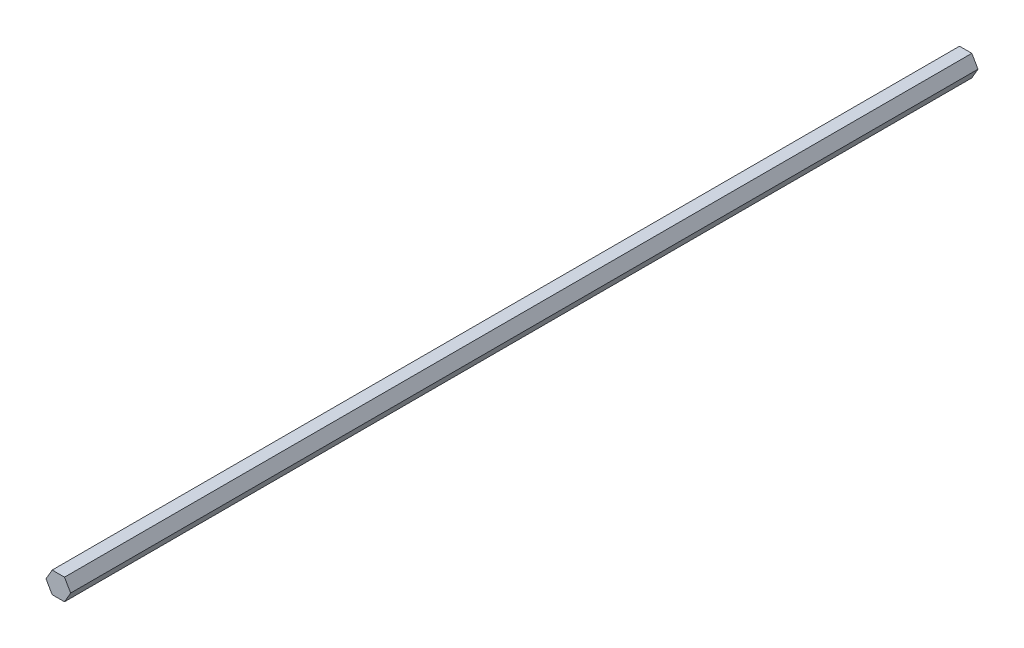
from build123d import *

# Parameters (mm, degrees)
BOSS_EXTRUDE1_DEPTH = 539.75


with BuildPart() as part:
    # Sketch1 → Boss-Extrude1 (new body)
    with BuildSketch(Plane.XY):
        Polygon((7.332348419, 0), (3.666174209, 6.35), (-3.666174209, 6.35), (-7.332348419, 0), (-3.666174209, -6.35), (3.666174209, -6.35), align=None)
    extrude(amount=BOSS_EXTRUDE1_DEPTH)


solid = part.part
